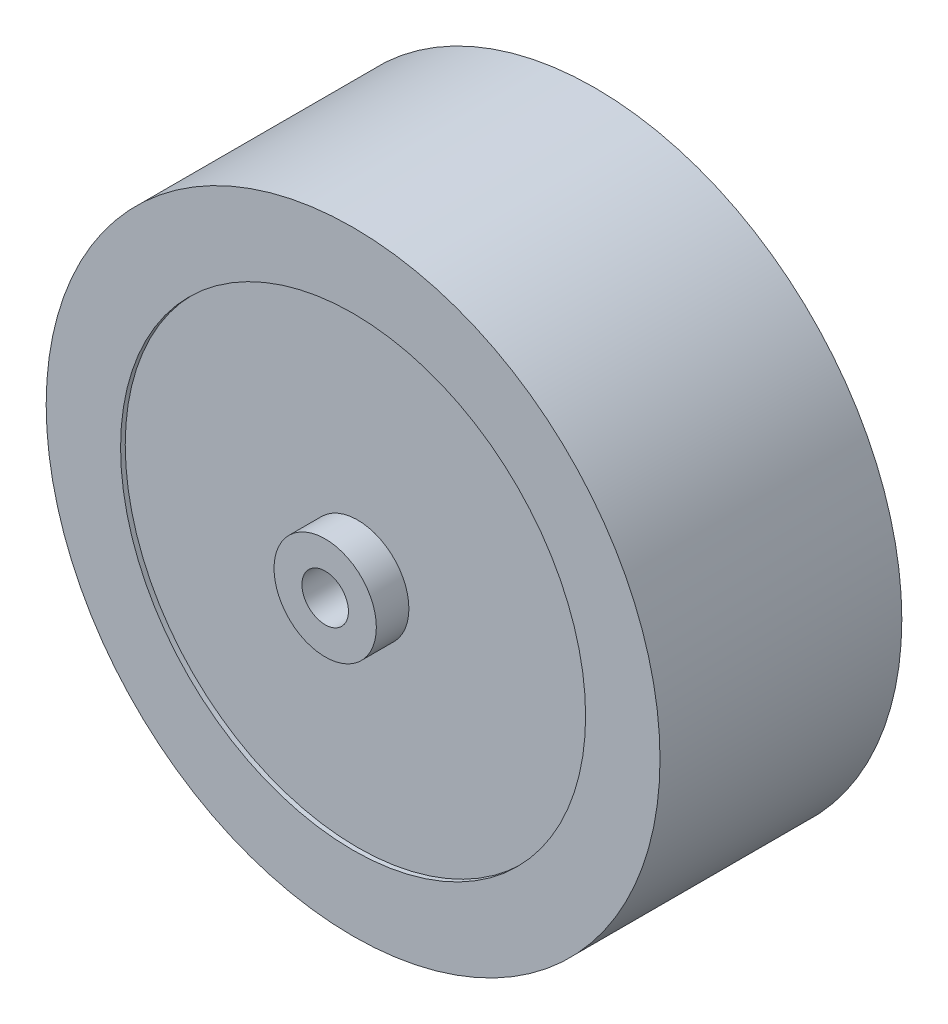
from build123d import *

# Parameters (mm, degrees)
ESTRUSIONE_ESTRUSIONE1_DEPTH      = 13
ESTRUSIONE_ESTRUSIONE1_DEPTH_BACK = 13
SCHIZZO1_R                        = 33
SCHIZZO1_R_2                      = 25
ESTRUSIONE_ESTRUSIONE2_DEPTH      = 12.5
ESTRUSIONE_ESTRUSIONE2_DEPTH_BACK = 12.5
SCHIZZO1_3_R                      = 25
SCHIZZO1_3_R_2                    = 2.5
SCHIZZO2_R                        = 5.5
SCHIZZO2_R_2                      = 2.5
ESTRUSIONE_ESTRUSIONE3_DEPTH      = 3.5


with BuildPart() as part:
    # Schizzo1 → Estrusione-Estrusione1 (new, two sides: drawn at the far end of the back side and taken through both)
    with BuildSketch(Plane.XY.offset(-ESTRUSIONE_ESTRUSIONE1_DEPTH_BACK)):
        Circle(SCHIZZO1_R)
        Circle(SCHIZZO1_R_2, mode=Mode.SUBTRACT)
    extrude(amount=ESTRUSIONE_ESTRUSIONE1_DEPTH + ESTRUSIONE_ESTRUSIONE1_DEPTH_BACK)

    # Schizzo1_3 → Estrusione-Estrusione2 (add, two sides: drawn at the far end of the back side and taken through both)
    with BuildSketch(Plane.XY.offset(-ESTRUSIONE_ESTRUSIONE2_DEPTH_BACK)):
        Circle(SCHIZZO1_3_R)
        Circle(SCHIZZO1_3_R_2, mode=Mode.SUBTRACT)
    extrude(amount=ESTRUSIONE_ESTRUSIONE2_DEPTH + ESTRUSIONE_ESTRUSIONE2_DEPTH_BACK)

    # Schizzo2 → Estrusione-Estrusione3 (add)
    with BuildSketch(Plane.XY.offset(12.5)):
        Circle(SCHIZZO2_R)
        Circle(SCHIZZO2_R_2, mode=Mode.SUBTRACT)
    extrude(amount=ESTRUSIONE_ESTRUSIONE3_DEPTH)


solid = part.part
